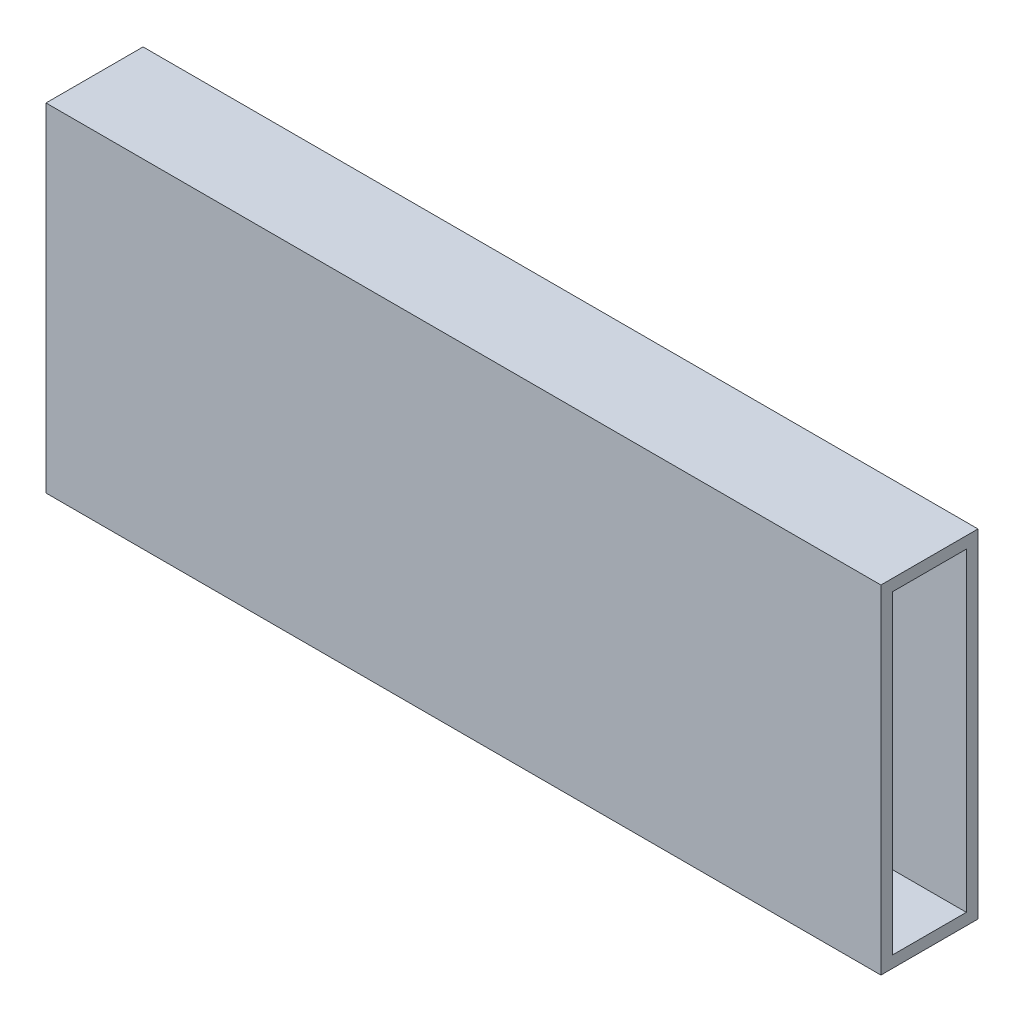
from build123d import *

# Parameters (mm, degrees)
SKETCH1_W           = 215
SKETCH1_H           = 25
BOSS_EXTRUDE1_DEPTH = 87
SKETCH3_W           = 19
SKETCH3_H           = 81
CUT_EXTRUDE1_DEPTH  = 216
SKETCH4_R           = 1.5
CUT_EXTRUDE2_DEPTH  = 3


with BuildPart() as part:
    # Sketch1 → Boss-Extrude1 (new body)
    with BuildSketch(Plane(origin=(0, 0, 0), x_dir=(1, 0, 0), z_dir=(0, 1, 0))):
        Rectangle(SKETCH1_W, SKETCH1_H)
    extrude(amount=BOSS_EXTRUDE1_DEPTH)

    # Sketch3 → Cut-Extrude1 (cut, through all)
    with BuildSketch(Plane.ZY.offset(107.5)):
        with Locations((0, 43.5)):
            Rectangle(SKETCH3_W, SKETCH3_H)
    extrude(amount=-CUT_EXTRUDE1_DEPTH, mode=Mode.SUBTRACT)

    # Sketch4 → Cut-Extrude2 (cut)
    with BuildSketch(Plane.XZ):
        with Locations((-50, 0)):
            Circle(SKETCH4_R)
        with Locations((50, 0)):
            Circle(SKETCH4_R)
    extrude(amount=-CUT_EXTRUDE2_DEPTH, mode=Mode.SUBTRACT)


solid = part.part
